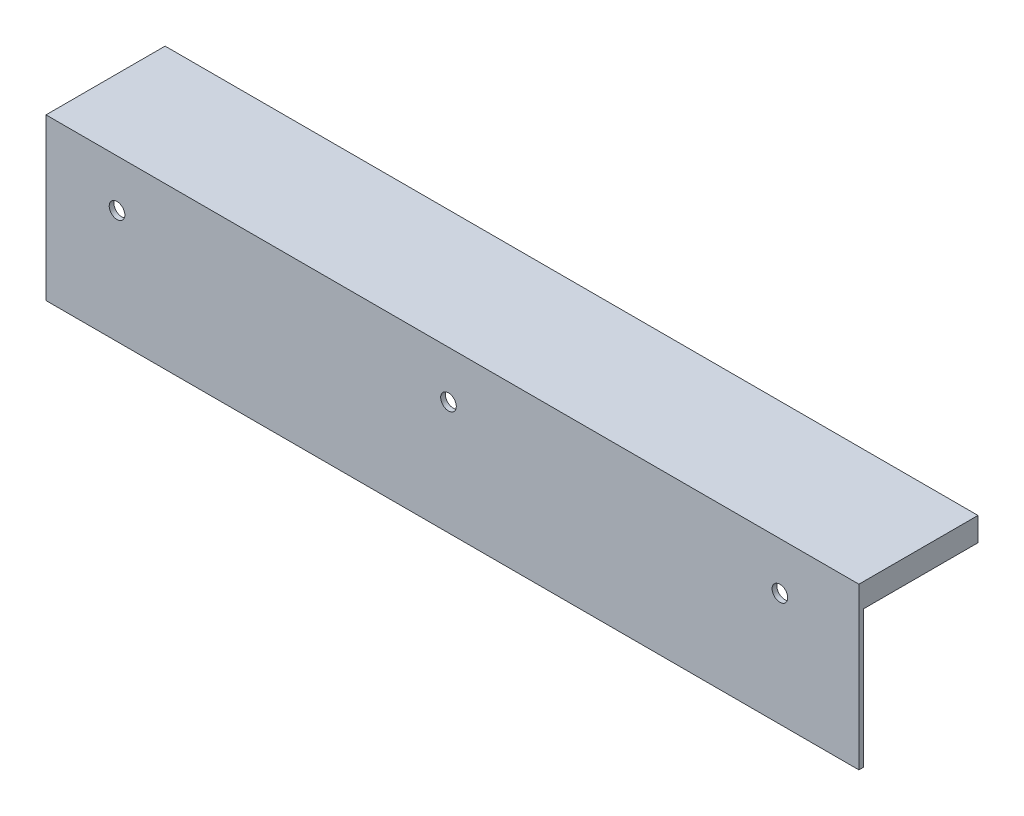
from build123d import *

# Parameters (mm, degrees)
SKETCH1_W           = 171.681197847
SKETCH1_H           = 28.969428325
SKETCH1_R           = 1.65
BOSS_EXTRUDE1_DEPTH = 1
SKETCH7_W           = 171.681197847
SKETCH7_H           = 25.151518983
BOSS_EXTRUDE2_DEPTH = 5


with BuildPart() as part:
    # Sketch1 → Boss-Extrude1 (new body)
    with BuildSketch(Plane.XY):
        with Locations((-137.259678888, 258.015285838)):
            Rectangle(SKETCH1_W, SKETCH1_H)
        with Locations((-208.100277812, 267.5)):
            Circle(SKETCH1_R, mode=Mode.SUBTRACT)
        with Locations((-138.100277812, 267.5)):
            Circle(SKETCH1_R, mode=Mode.SUBTRACT)
        with Locations((-68.100277811, 267.5)):
            Circle(SKETCH1_R, mode=Mode.SUBTRACT)
    extrude(amount=BOSS_EXTRUDE1_DEPTH)

    # Sketch7 → Boss-Extrude2 (add)
    with BuildSketch(Plane(origin=(0, 272.5, 0), x_dir=(1, 0, 0), z_dir=(0, 1, 0))):
        with Locations((-137.259678888, 11.575759492)):
            Rectangle(SKETCH7_W, SKETCH7_H)
    extrude(amount=BOSS_EXTRUDE2_DEPTH)


solid = part.part
